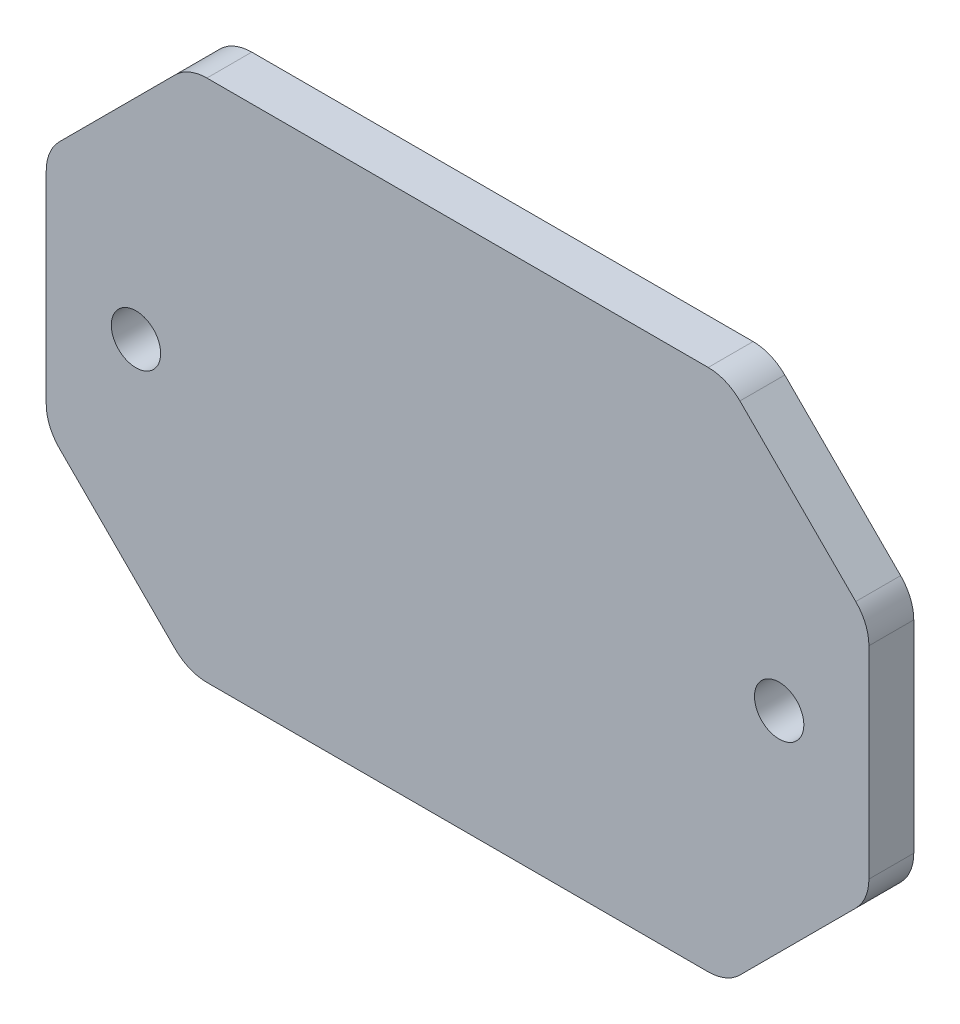
from build123d import *

# Parameters (mm, degrees)
SKETCH_1_W          = 55
SKETCH_1_H          = 34.996183206
EXTRUDE_1_DEPTH     = 3
CHAMFER_1_SIZE      = 9.5
FILLET_1_R          = 3
SKETCH_2_R          = 1.65
CUT_EXTRUDE_1_DEPTH = 4


with BuildPart() as part:
    # 草图1 → 凸台-拉伸1 (new body)
    with BuildSketch(Plane.XY):
        Rectangle(SKETCH_1_W, SKETCH_1_H)
    extrude(amount=EXTRUDE_1_DEPTH)

    # 倒角1
    chamfer_1_edges = [part.edges().sort_by_distance(p)[0] for p in [
        (27.5, -17.498091603, 1.5),
        (-27.5, -17.498091603, 1.5),
        (-27.5, 17.498091603, 1.5),
        (27.5, 17.498091603, 1.5),
    ]]
    chamfer(chamfer_1_edges, length=CHAMFER_1_SIZE)

    # 圆角1
    fillet_1_edges = [part.edges().sort_by_distance(p)[0] for p in [
        (-27.5, -7.998091603, 1.5),
        (-27.5, 7.998091603, 1.5),
        (18, 17.498091603, 1.5),
        (-18, 17.498091603, 1.5),
        (18, -17.498091603, 1.5),
        (-18, -17.498091603, 1.5),
        (27.5, 7.998091603, 1.5),
        (27.5, -7.998091603, 1.5),
    ]]
    fillet(fillet_1_edges, radius=FILLET_1_R)

    # 草图2 → 切除-拉伸1 (cut, through all)
    with BuildSketch(Plane.XY.offset(3)):
        with Locations((-21.5, 0)):
            Circle(SKETCH_2_R)
        with Locations((21.5, 0)):
            Circle(SKETCH_2_R)
    extrude(amount=-CUT_EXTRUDE_1_DEPTH, mode=Mode.SUBTRACT)


solid = part.part
